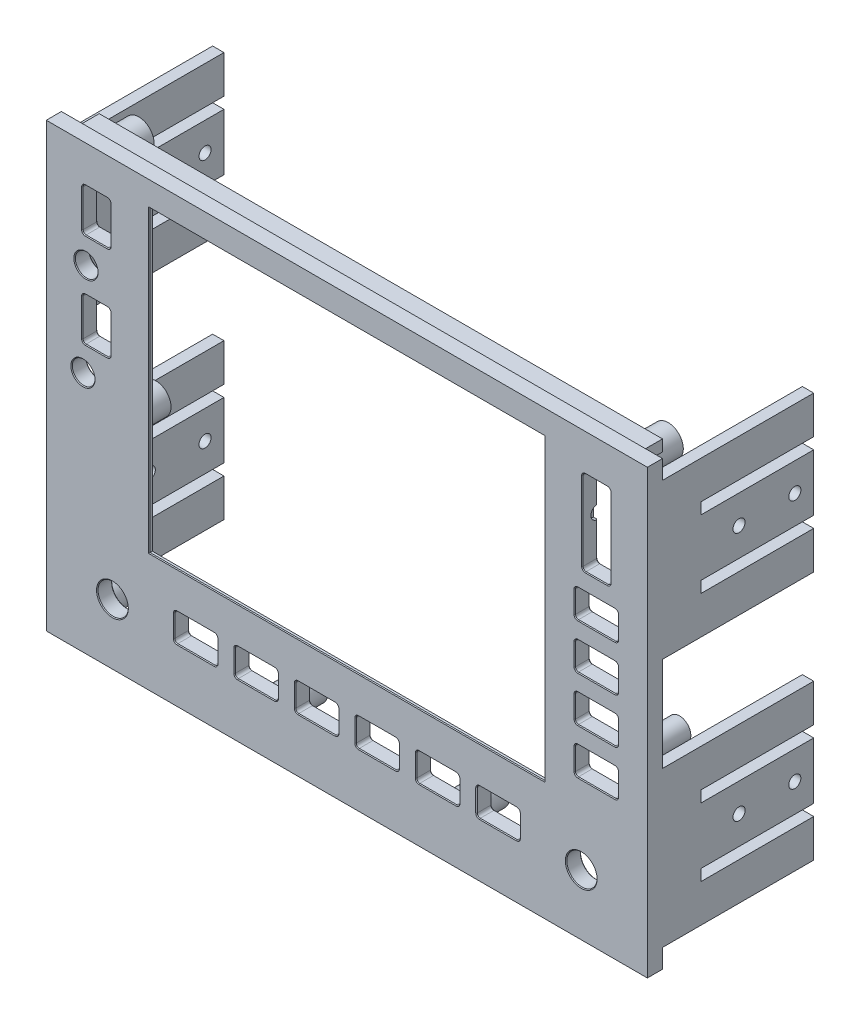
from build123d import *

# Parameters (mm, degrees)
ESQUISSE1_W                  = 160
ESQUISSE1_H                  = 117
BOSS_EXTRU_1_DEPTH           = 4
ESQUISSE3_W                  = 104.5
ESQUISSE3_H                  = 79
ENL_V_MAT_EXTRU_2_DEPTH      = 4
ESQUISSE14_W                 = 3
ESQUISSE14_H                 = 41
BOSS_EXTRU_3_DEPTH           = 40
ESQUISSE15_R                 = 1.6
ESQUISSE15_W                 = 29.751261147
ESQUISSE15_H                 = 3
ENL_V_MAT_EXTRU_8_DEPTH      = 161
ESQUISSE16_W                 = 31.071550454
ESQUISSE16_H                 = 132.180055176
ESQUISSE16_W_2               = 12.596574509
ESQUISSE16_H_2               = 136.043004691
ENL_V_MAT_EXTRU_9_DEPTH      = 45
ESQUISSE9_W                  = 118.5
ESQUISSE9_H                  = 89
ENL_V_MAT_EXTRU_5_DEPTH      = 3
ESQUISSE4_R                  = 4
ENL_V_MAT_EXTRU_3_DEPTH      = 4
ESQUISSE12_R                 = 4
ESQUISSE12_R_2               = 1.425
BOSS_EXTRU_2_DEPTH           = 11
ESQUISSE12_R_3               = 3
BOSS_EXTRU_2_2_DEPTH         = 11
BOSS_EXTRU_2_3_DEPTH         = 11
BOSS_EXTRU_2_4_DEPTH         = 11
BOSS_EXTRU_2_5_DEPTH         = 11
BOSS_EXTRU_2_6_DEPTH         = 11
BOSS_EXTRU_2_7_DEPTH         = 11
BOSS_EXTRU_2_8_DEPTH         = 11
BOSS_EXTRU_2_9_DEPTH         = 11
ESQUISSE10_R                 = 3
ENL_V_MAT_EXTRU_6_DEPTH      = 30
ENL_V_MAT_EXTRU_6_DEPTH_BACK = 4
ESQUISSE11_R                 = 1.75
ENL_V_MAT_EXTRU_7_DEPTH      = 8.5
ENL_V_MAT_EXTRU_7_DEPTH_BACK = 1.5
CHANFREIN2_SIZE              = 0.2
CHANFREIN3_SIZE              = 0.2
ESQUISSE17_W                 = 149
ESQUISSE17_H                 = 4
ESQUISSE17_H_2               = 3
BOSS_EXTRU_4_DEPTH           = 5


with BuildPart() as part:
    # Esquisse1 → Boss.-Extru.1 (new body)
    with BuildSketch(Plane.XY):
        with Locations((80, 58.5)):
            Rectangle(ESQUISSE1_W, ESQUISSE1_H)
    extrude(amount=BOSS_EXTRU_1_DEPTH)

    # Esquisse3 → Enlèv. mat.-Extru.2 (cut)
    with BuildSketch(Plane.XY.offset(4)):
        with Locations((80, 71)):
            Rectangle(ESQUISSE3_W, ESQUISSE3_H)
    extrude(amount=-ENL_V_MAT_EXTRU_2_DEPTH, mode=Mode.SUBTRACT)

    # Esquisse14 → Boss.-Extru.3 (add)
    with BuildSketch(Plane(origin=(0, 0, 0), x_dir=(-1, 0, 0), z_dir=(0, 0, -1))):
        with Locations((-158, 25.5)):
            Rectangle(ESQUISSE14_W, ESQUISSE14_H)
        with Locations((-158, 91.5)):
            Rectangle(ESQUISSE14_W, ESQUISSE14_H)
        with Locations((-2, 25.5)):
            Rectangle(ESQUISSE14_W, ESQUISSE14_H)
        with Locations((-2, 91.5)):
            Rectangle(ESQUISSE14_W, ESQUISSE14_H)
    extrude(amount=BOSS_EXTRU_3_DEPTH)

    # Esquisse15 → Enlèv. mat.-Extru.8 (cut, through all)
    with BuildSketch(Plane(origin=(160, 0, 0), x_dir=(0, 0, -1), z_dir=(1, 0, 0))):
        with Locations((35, 91.5)):
            Circle(ESQUISSE15_R)
        with Locations((35, 25.5)):
            Circle(ESQUISSE15_R)
        with Locations((20.248738853, 91.5)):
            Circle(ESQUISSE15_R)
        with Locations((20.248738853, 25.5)):
            Circle(ESQUISSE15_R)
        with Locations((25.124369426, 100.5)):
            Rectangle(ESQUISSE15_W, ESQUISSE15_H)
        with Locations((25.124369426, 82.5)):
            Rectangle(ESQUISSE15_W, ESQUISSE15_H)
        with Locations((25.124369426, 34.5)):
            Rectangle(ESQUISSE15_W, ESQUISSE15_H)
        with Locations((25.124369426, 16.5)):
            Rectangle(ESQUISSE15_W, ESQUISSE15_H)
    extrude(amount=-ENL_V_MAT_EXTRU_8_DEPTH, mode=Mode.SUBTRACT)

    # Esquisse16 → Enlèv. mat.-Extru.9 (cut, through all)
    with BuildSketch(Plane.XY.offset(4)):
        with Locations((-15.035775227, 59.507713461)):
            Rectangle(ESQUISSE16_W, ESQUISSE16_H)
        with Locations((165.798287254, 59.255781971)):
            Rectangle(ESQUISSE16_W_2, ESQUISSE16_H_2)
    extrude(amount=-ENL_V_MAT_EXTRU_9_DEPTH, mode=Mode.SUBTRACT)

    # Esquisse9 → Enlèv. mat.-Extru.5 (cut)
    with BuildSketch(Plane(origin=(0, 0, 0), x_dir=(-1, 0, 0), z_dir=(0, 0, -1))):
        with Locations((-80, 68.5)):
            Rectangle(ESQUISSE9_W, ESQUISSE9_H)
    extrude(amount=-ENL_V_MAT_EXTRU_5_DEPTH, mode=Mode.SUBTRACT)

    # Esquisse4 → Enlèv. mat.-Extru.3 (cut)
    with BuildSketch(Plane.XY.offset(4)):
        with Locations((142, 16)):
            Circle(ESQUISSE4_R)
        with Locations((18, 16)):
            Circle(ESQUISSE4_R)
    extrude(amount=-ENL_V_MAT_EXTRU_3_DEPTH, mode=Mode.SUBTRACT)

    # Esquisse10 → Enlèv. mat.-Extru.6 (cut, two sides)
    with BuildSketch(Plane(origin=(0, 0, 0), x_dir=(-1, 0, 0), z_dir=(0, 0, -1))) as enl_v_mat_extru_6_sk:
        with Locations((-11, 89)):
            Circle(ESQUISSE10_R)
        with Locations((-10.2, 64)):
            Circle(ESQUISSE10_R)
        with BuildLine():
            Line((-124.9, 21.7), (-115.1, 21.7))
            ThreePointArc((-115.1, 21.7), (-114.534314575, 21.465685425), (-114.3, 20.9))
            Line((-114.3, 20.9), (-114.3, 15.1))
            ThreePointArc((-114.3, 15.1), (-114.534314575, 14.534314575), (-115.1, 14.3))
            Line((-115.1, 14.3), (-124.9, 14.3))
            ThreePointArc((-124.9, 14.3), (-125.465685425, 14.534314575), (-125.7, 15.1))
            Line((-125.7, 15.1), (-125.7, 20.9))
            ThreePointArc((-125.7, 20.9), (-125.465685425, 21.465685425), (-124.9, 21.7))
        make_face()
        with BuildLine():
            Line((-108.9, 21.7), (-99.1, 21.7))
            ThreePointArc((-99.1, 21.7), (-98.534314575, 21.465685425), (-98.3, 20.9))
            Line((-98.3, 20.9), (-98.3, 15.1))
            ThreePointArc((-98.3, 15.1), (-98.534314575, 14.534314575), (-99.1, 14.3))
            Line((-99.1, 14.3), (-108.9, 14.3))
            ThreePointArc((-108.9, 14.3), (-109.465685425, 14.534314575), (-109.7, 15.1))
            Line((-109.7, 15.1), (-109.7, 20.9))
            ThreePointArc((-109.7, 20.9), (-109.465685425, 21.465685425), (-108.9, 21.7))
        make_face()
        with BuildLine():
            Line((-92.9, 21.7), (-83.1, 21.7))
            ThreePointArc((-83.1, 21.7), (-82.534314575, 21.465685425), (-82.3, 20.9))
            Line((-82.3, 20.9), (-82.3, 15.1))
            ThreePointArc((-82.3, 15.1), (-82.534314575, 14.534314575), (-83.1, 14.3))
            Line((-83.1, 14.3), (-92.9, 14.3))
            ThreePointArc((-92.9, 14.3), (-93.465685425, 14.534314575), (-93.7, 15.1))
            Line((-93.7, 15.1), (-93.7, 20.9))
            ThreePointArc((-93.7, 20.9), (-93.465685425, 21.465685425), (-92.9, 21.7))
        make_face()
        with BuildLine():
            Line((-76.9, 21.7), (-67.1, 21.7))
            ThreePointArc((-67.1, 21.7), (-66.534314575, 21.465685425), (-66.3, 20.9))
            Line((-66.3, 20.9), (-66.3, 15.1))
            ThreePointArc((-66.3, 15.1), (-66.534314575, 14.534314575), (-67.1, 14.3))
            Line((-67.1, 14.3), (-76.9, 14.3))
            ThreePointArc((-76.9, 14.3), (-77.465685425, 14.534314575), (-77.7, 15.1))
            Line((-77.7, 15.1), (-77.7, 20.9))
            ThreePointArc((-77.7, 20.9), (-77.465685425, 21.465685425), (-76.9, 21.7))
        make_face()
        with BuildLine():
            Line((-60.9, 21.7), (-51.1, 21.7))
            ThreePointArc((-51.1, 21.7), (-50.534314575, 21.465685425), (-50.3, 20.9))
            Line((-50.3, 20.9), (-50.3, 15.1))
            ThreePointArc((-50.3, 15.1), (-50.534314575, 14.534314575), (-51.1, 14.3))
            Line((-51.1, 14.3), (-60.9, 14.3))
            ThreePointArc((-60.9, 14.3), (-61.465685425, 14.534314575), (-61.7, 15.1))
            Line((-61.7, 15.1), (-61.7, 20.9))
            ThreePointArc((-61.7, 20.9), (-61.465685425, 21.465685425), (-60.9, 21.7))
        make_face()
        with BuildLine():
            Line((-44.9, 21.7), (-35.1, 21.7))
            ThreePointArc((-35.1, 21.7), (-34.534314575, 21.465685425), (-34.3, 20.9))
            Line((-34.3, 20.9), (-34.3, 15.1))
            ThreePointArc((-34.3, 15.1), (-34.534314575, 14.534314575), (-35.1, 14.3))
            Line((-35.1, 14.3), (-44.9, 14.3))
            ThreePointArc((-44.9, 14.3), (-45.465685425, 14.534314575), (-45.7, 15.1))
            Line((-45.7, 15.1), (-45.7, 20.9))
            ThreePointArc((-45.7, 20.9), (-45.465685425, 21.465685425), (-44.9, 21.7))
        make_face()
        with BuildLine():
            Line((-148.9, 107.2), (-143.1, 107.2))
            ThreePointArc((-143.1, 107.2), (-142.534314575, 106.965685425), (-142.3, 106.4))
            Line((-142.3, 106.4), (-142.3, 85.6))
            ThreePointArc((-142.3, 85.6), (-142.534314575, 85.034314575), (-143.1, 84.8))
            Line((-143.1, 84.8), (-148.9, 84.8))
            ThreePointArc((-148.9, 84.8), (-149.465685425, 85.034314575), (-149.7, 85.6))
            Line((-149.7, 85.6), (-149.7, 106.4))
            ThreePointArc((-149.7, 106.4), (-149.465685425, 106.965685425), (-148.9, 107.2))
        make_face()
        with BuildLine():
            Line((-150.9, 80.2), (-141.1, 80.2))
            ThreePointArc((-141.1, 80.2), (-140.534314575, 79.965685425), (-140.3, 79.4))
            Line((-140.3, 79.4), (-140.3, 73.6))
            ThreePointArc((-140.3, 73.6), (-140.534314575, 73.034314575), (-141.1, 72.8))
            Line((-141.1, 72.8), (-150.9, 72.8))
            ThreePointArc((-150.9, 72.8), (-151.465685425, 73.034314575), (-151.7, 73.6))
            Line((-151.7, 73.6), (-151.7, 79.4))
            ThreePointArc((-151.7, 79.4), (-151.465685425, 79.965685425), (-150.9, 80.2))
        make_face()
        with BuildLine():
            Line((-150.9, 68.2), (-141.1, 68.2))
            ThreePointArc((-141.1, 68.2), (-140.534314575, 67.965685425), (-140.3, 67.4))
            Line((-140.3, 67.4), (-140.3, 61.6))
            ThreePointArc((-140.3, 61.6), (-140.534314575, 61.034314575), (-141.1, 60.8))
            Line((-141.1, 60.8), (-150.9, 60.8))
            ThreePointArc((-150.9, 60.8), (-151.465685425, 61.034314575), (-151.7, 61.6))
            Line((-151.7, 61.6), (-151.7, 67.4))
            ThreePointArc((-151.7, 67.4), (-151.465685425, 67.965685425), (-150.9, 68.2))
        make_face()
        with BuildLine():
            Line((-150.9, 56.2), (-141.1, 56.2))
            ThreePointArc((-141.1, 56.2), (-140.534314575, 55.965685425), (-140.3, 55.4))
            Line((-140.3, 55.4), (-140.3, 49.6))
            ThreePointArc((-140.3, 49.6), (-140.534314575, 49.034314575), (-141.1, 48.8))
            Line((-141.1, 48.8), (-150.9, 48.8))
            ThreePointArc((-150.9, 48.8), (-151.465685425, 49.034314575), (-151.7, 49.6))
            Line((-151.7, 49.6), (-151.7, 55.4))
            ThreePointArc((-151.7, 55.4), (-151.465685425, 55.965685425), (-150.9, 56.2))
        make_face()
        with BuildLine():
            Line((-150.9, 44.2), (-141.1, 44.2))
            ThreePointArc((-141.1, 44.2), (-140.534314575, 43.965685425), (-140.3, 43.4))
            Line((-140.3, 43.4), (-140.3, 37.6))
            ThreePointArc((-140.3, 37.6), (-140.534314575, 37.034314575), (-141.1, 36.8))
            Line((-141.1, 36.8), (-150.9, 36.8))
            ThreePointArc((-150.9, 36.8), (-151.465685425, 37.034314575), (-151.7, 37.6))
            Line((-151.7, 37.6), (-151.7, 43.4))
            ThreePointArc((-151.7, 43.4), (-151.465685425, 43.965685425), (-150.9, 44.2))
        make_face()
        with BuildLine():
            Line((-16.65, 107.2), (-10.85, 107.2))
            ThreePointArc((-10.85, 107.2), (-10.284314575, 106.965685425), (-10.05, 106.4))
            Line((-10.05, 106.4), (-10.05, 96.6))
            ThreePointArc((-10.05, 96.6), (-10.284314575, 96.034314575), (-10.85, 95.8))
            Line((-10.85, 95.8), (-16.65, 95.8))
            ThreePointArc((-16.65, 95.8), (-17.215685425, 96.034314575), (-17.45, 96.6))
            Line((-17.45, 96.6), (-17.45, 106.4))
            ThreePointArc((-17.45, 106.4), (-17.215685425, 106.965685425), (-16.65, 107.2))
        make_face()
        with BuildLine():
            Line((-16.65, 82.2), (-10.85, 82.2))
            ThreePointArc((-10.85, 82.2), (-10.284314575, 81.965685425), (-10.05, 81.4))
            Line((-10.05, 81.4), (-10.05, 71.6))
            ThreePointArc((-10.05, 71.6), (-10.284314575, 71.034314575), (-10.85, 70.8))
            Line((-10.85, 70.8), (-16.65, 70.8))
            ThreePointArc((-16.65, 70.8), (-17.215685425, 71.034314575), (-17.45, 71.6))
            Line((-17.45, 71.6), (-17.45, 81.4))
            ThreePointArc((-17.45, 81.4), (-17.215685425, 81.965685425), (-16.65, 82.2))
        make_face()
    extrude(amount=ENL_V_MAT_EXTRU_6_DEPTH, mode=Mode.SUBTRACT)
    extrude(enl_v_mat_extru_6_sk.sketch, amount=-ENL_V_MAT_EXTRU_6_DEPTH_BACK, mode=Mode.SUBTRACT)

    # Esquisse11 → Enlèv. mat.-Extru.7 (cut, two sides)
    with BuildSketch(Plane.ZY.offset(-149.7)) as enl_v_mat_extru_7_sk:
        with Locations((0, 96.2)):
            Circle(ESQUISSE11_R)
    extrude(amount=ENL_V_MAT_EXTRU_7_DEPTH, mode=Mode.SUBTRACT)
    extrude(enl_v_mat_extru_7_sk.sketch, amount=-ENL_V_MAT_EXTRU_7_DEPTH_BACK, mode=Mode.SUBTRACT)

    # Chanfrein2
    chanfrein2_edges = [part.edges().sort_by_distance(p)[0] for p in [
        (80, 110.5, 4),
        (80, 31.5, 3),
        (139.25, 68.5, 0),
        (80, 24, 0),
        (20.75, 68.5, 0),
        (80, 113, 0),
        (80, 110.5, 3),
        (27.75, 71, 3),
        (132.25, 71, 3),
        (138, 16, 0),
        (138, 16, 4),
        (14, 16, 0),
        (14, 16, 4),
        (45.465685425, 14.534314575, 0),
        (45.465685425, 14.534314575, 4),
        (40, 14.3, 0),
        (40, 14.3, 4),
        (34.534314575, 14.534314575, 0),
        (34.534314575, 14.534314575, 4),
        (34.3, 18, 0),
        (34.3, 18, 4),
        (34.534314575, 21.465685425, 0),
        (34.534314575, 21.465685425, 4),
        (40, 21.7, 0),
        (40, 21.7, 4),
        (45.465685425, 21.465685425, 0),
        (45.465685425, 21.465685425, 4),
        (45.7, 18, 0),
        (45.7, 18, 4),
        (50.534314575, 21.465685425, 0),
        (50.534314575, 21.465685425, 4),
        (56, 21.7, 0),
        (56, 21.7, 4),
        (61.465685425, 21.465685425, 0),
        (61.465685425, 21.465685425, 4),
        (61.7, 18, 0),
        (61.7, 18, 4),
        (61.465685425, 14.534314575, 0),
        (61.465685425, 14.534314575, 4),
        (56, 14.3, 0),
        (56, 14.3, 4),
        (50.534314575, 14.534314575, 0),
        (50.534314575, 14.534314575, 4),
        (50.3, 18, 0),
        (50.3, 18, 4),
        (66.534314575, 21.465685425, 0),
        (66.534314575, 21.465685425, 4),
        (72, 21.7, 0),
        (72, 21.7, 4),
        (77.465685425, 21.465685425, 0),
        (77.465685425, 21.465685425, 4),
        (77.7, 18, 0),
        (77.7, 18, 4),
        (77.465685425, 14.534314575, 0),
        (77.465685425, 14.534314575, 4),
        (72, 14.3, 0),
        (72, 14.3, 4),
        (66.534314575, 14.534314575, 0),
        (66.534314575, 14.534314575, 4),
        (66.3, 18, 0),
        (66.3, 18, 4),
        (82.534314575, 21.465685425, 0),
        (82.534314575, 21.465685425, 4),
        (88, 21.7, 0),
        (88, 21.7, 4),
        (93.465685425, 21.465685425, 0),
        (93.465685425, 21.465685425, 4),
        (93.7, 18, 0),
        (93.7, 18, 4),
        (93.465685425, 14.534314575, 0),
        (93.465685425, 14.534314575, 4),
        (88, 14.3, 0),
        (88, 14.3, 4),
        (82.534314575, 14.534314575, 0),
        (82.534314575, 14.534314575, 4),
        (82.3, 18, 0),
        (82.3, 18, 4),
        (98.534314575, 21.465685425, 0),
        (98.534314575, 21.465685425, 4),
        (104, 21.7, 0),
        (104, 21.7, 4),
        (109.465685425, 21.465685425, 0),
        (109.465685425, 21.465685425, 4),
        (109.7, 18, 0),
        (109.7, 18, 4),
        (109.465685425, 14.534314575, 0),
        (109.465685425, 14.534314575, 4),
        (104, 14.3, 0),
        (104, 14.3, 4),
        (98.534314575, 14.534314575, 0),
        (98.534314575, 14.534314575, 4),
        (98.3, 18, 0),
        (98.3, 18, 4),
        (114.534314575, 21.465685425, 0),
        (114.534314575, 21.465685425, 4),
        (120, 21.7, 0),
        (120, 21.7, 4),
        (125.465685425, 21.465685425, 0),
        (125.465685425, 21.465685425, 4),
        (125.7, 18, 0),
        (125.7, 18, 4),
        (125.465685425, 14.534314575, 0),
        (125.465685425, 14.534314575, 4),
        (120, 14.3, 0),
        (120, 14.3, 4),
        (114.534314575, 14.534314575, 0),
        (114.534314575, 14.534314575, 4),
        (114.3, 18, 0),
        (114.3, 18, 4),
        (151.465685425, 43.965685425, 0),
        (151.465685425, 43.965685425, 4),
        (151.7, 40.5, 0),
        (151.7, 40.5, 4),
        (151.465685425, 37.034314575, 0),
        (151.465685425, 37.034314575, 4),
        (146, 36.8, 0),
        (146, 36.8, 4),
        (140.534314575, 37.034314575, 0),
        (140.534314575, 37.034314575, 4),
        (140.3, 40.5, 0),
        (140.3, 40.5, 4),
        (140.534314575, 43.965685425, 0),
        (140.534314575, 43.965685425, 4),
        (146, 44.2, 0),
        (146, 44.2, 4),
        (140.534314575, 55.965685425, 0),
        (140.534314575, 55.965685425, 4),
        (146, 56.2, 0),
        (146, 56.2, 4),
        (151.465685425, 55.965685425, 0),
        (151.465685425, 55.965685425, 4),
        (151.7, 52.5, 0),
        (151.7, 52.5, 4),
        (151.465685425, 49.034314575, 0),
        (151.465685425, 49.034314575, 4),
        (146, 48.8, 0),
        (146, 48.8, 4),
        (140.534314575, 49.034314575, 0),
        (140.534314575, 49.034314575, 4),
        (140.3, 52.5, 0),
        (140.3, 52.5, 4),
        (151.465685425, 67.965685425, 0),
        (151.465685425, 67.965685425, 4),
        (151.7, 64.5, 0),
        (151.7, 64.5, 4),
        (151.465685425, 61.034314575, 0),
        (151.465685425, 61.034314575, 4),
        (146, 60.8, 0),
        (146, 60.8, 4),
        (140.534314575, 61.034314575, 0),
        (140.534314575, 61.034314575, 4),
        (140.3, 64.5, 0),
        (140.3, 64.5, 4),
        (140.534314575, 67.965685425, 0),
        (140.534314575, 67.965685425, 4),
        (146, 68.2, 0),
        (146, 68.2, 4),
        (140.534314575, 73.034314575, 0),
        (140.534314575, 73.034314575, 4),
        (140.3, 76.5, 0),
        (140.3, 76.5, 4),
        (140.534314575, 79.965685425, 0),
        (140.534314575, 79.965685425, 4),
        (146, 80.2, 0),
        (146, 80.2, 4),
        (151.465685425, 79.965685425, 0),
        (151.465685425, 79.965685425, 4),
        (151.7, 76.5, 0),
        (151.7, 76.5, 4),
        (151.465685425, 73.034314575, 0),
        (151.465685425, 73.034314575, 4),
        (146, 72.8, 0),
        (146, 72.8, 4),
        (149.465685425, 85.034314575, 0),
        (149.465685425, 85.034314575, 4),
        (146, 84.8, 0),
        (146, 84.8, 4),
        (142.534314575, 85.034314575, 0),
        (142.534314575, 85.034314575, 4),
        (142.3, 102.175, 0),
        (142.3, 96, 4),
        (142.534314575, 106.965685425, 0),
        (142.534314575, 106.965685425, 4),
        (146, 107.2, 0),
        (146, 107.2, 4),
        (149.465685425, 106.965685425, 0),
        (149.465685425, 106.965685425, 4),
        (149.7, 90.025, 0),
        (149.7, 96, 4),
        (14, 89, 0),
        (14, 89, 4),
        (13.2, 64, 0),
        (13.2, 64, 4),
        (10.284314575, 81.965685425, 0),
        (10.284314575, 81.965685425, 4),
        (13.75, 82.2, 0),
        (13.75, 82.2, 4),
        (17.215685425, 81.965685425, 0),
        (17.215685425, 81.965685425, 4),
        (17.45, 76.5, 0),
        (17.45, 76.5, 4),
        (17.215685425, 71.034314575, 0),
        (17.215685425, 71.034314575, 4),
        (13.75, 70.8, 0),
        (13.75, 70.8, 4),
        (10.284314575, 71.034314575, 0),
        (10.284314575, 71.034314575, 4),
        (10.05, 76.5, 0),
        (10.05, 76.5, 4),
        (10.284314575, 96.034314575, 0),
        (10.284314575, 96.034314575, 4),
        (10.05, 101.5, 0),
        (10.05, 101.5, 4),
        (10.284314575, 106.965685425, 0),
        (10.284314575, 106.965685425, 4),
        (13.75, 107.2, 0),
        (13.75, 107.2, 4),
        (17.215685425, 106.965685425, 0),
        (17.215685425, 106.965685425, 4),
        (17.45, 101.5, 0),
        (17.45, 101.5, 4),
        (17.215685425, 96.034314575, 0),
        (17.215685425, 96.034314575, 4),
        (13.75, 95.8, 0),
        (13.75, 95.8, 4),
        (149.7, 102.175, 0),
        (142.3, 90.025, 0),
    ]]
    chamfer(chanfrein2_edges, length=CHANFREIN2_SIZE)

    # Chanfrein3
    chanfrein3_edges = [part.edges().sort_by_distance(p)[0] for p in [
        (132.25, 71, 4),
        (80, 31.5, 4),
        (27.75, 71, 4),
    ]]
    chamfer(chanfrein3_edges, length=CHANFREIN3_SIZE)

    # Esquisse17 → Boss.-Extru.4 (add)
    with BuildSketch(Plane(origin=(0, 0, 0), x_dir=(-1, 0, 0), z_dir=(0, 0, -1))):
        with Locations((-80, 2.5)):
            Rectangle(ESQUISSE17_W, ESQUISSE17_H)
        with Locations((-80, 115)):
            Rectangle(ESQUISSE17_W, ESQUISSE17_H_2)
    extrude(amount=BOSS_EXTRU_4_DEPTH)


with BuildPart() as body_2:
    # Esquisse12 → Boss.-Extru.2 (new body)
    with BuildSketch(Plane(origin=(0, 0, 0), x_dir=(-1, 0, 0), z_dir=(0, 0, -1))):
        with Locations((-150, 111)):
            Circle(ESQUISSE12_R)
        with Locations((-150, 111)):
            Circle(ESQUISSE12_R_2, mode=Mode.SUBTRACT)
    extrude(amount=BOSS_EXTRU_2_DEPTH)


with BuildPart() as body_3:
    # Esquisse12 → Boss.-Extru.2 2 (new body)
    with BuildSketch(Plane(origin=(0, 0, 0), x_dir=(-1, 0, 0), z_dir=(0, 0, -1))):
        with Locations((-153, 70.312347561)):
            Circle(ESQUISSE12_R_3)
        with Locations((-153, 70.312347561)):
            Circle(ESQUISSE12_R_2, mode=Mode.SUBTRACT)
    extrude(amount=BOSS_EXTRU_2_2_DEPTH)


with BuildPart() as body_4:
    # Esquisse12 → Boss.-Extru.2 3 (new body)
    with BuildSketch(Plane(origin=(0, 0, 0), x_dir=(-1, 0, 0), z_dir=(0, 0, -1))):
        with Locations((-152.999695464, 46.312347563)):
            Circle(ESQUISSE12_R_3)
        with Locations((-152.999695464, 46.312347563)):
            Circle(ESQUISSE12_R_2, mode=Mode.SUBTRACT)
    extrude(amount=BOSS_EXTRU_2_3_DEPTH)


with BuildPart() as body_5:
    # Esquisse12 → Boss.-Extru.2 4 (new body)
    with BuildSketch(Plane(origin=(0, 0, 0), x_dir=(-1, 0, 0), z_dir=(0, 0, -1))):
        with Locations((-152, 8)):
            Circle(ESQUISSE12_R)
        with Locations((-152, 8)):
            Circle(ESQUISSE12_R_2, mode=Mode.SUBTRACT)
    extrude(amount=BOSS_EXTRU_2_4_DEPTH)


with BuildPart() as body_6:
    # Esquisse12 → Boss.-Extru.2 5 (new body)
    with BuildSketch(Plane(origin=(0, 0, 0), x_dir=(-1, 0, 0), z_dir=(0, 0, -1))):
        with Locations((-104, 8)):
            Circle(ESQUISSE12_R)
        with Locations((-104, 8)):
            Circle(ESQUISSE12_R_2, mode=Mode.SUBTRACT)
    extrude(amount=BOSS_EXTRU_2_5_DEPTH)


with BuildPart() as body_7:
    # Esquisse12 → Boss.-Extru.2 6 (new body)
    with BuildSketch(Plane(origin=(0, 0, 0), x_dir=(-1, 0, 0), z_dir=(0, 0, -1))):
        with Locations((-56, 8)):
            Circle(ESQUISSE12_R)
        with Locations((-56, 8)):
            Circle(ESQUISSE12_R_2, mode=Mode.SUBTRACT)
    extrude(amount=BOSS_EXTRU_2_6_DEPTH)


with BuildPart() as body_8:
    # Esquisse12 → Boss.-Extru.2 7 (new body)
    with BuildSketch(Plane(origin=(0, 0, 0), x_dir=(-1, 0, 0), z_dir=(0, 0, -1))):
        with Locations((-8, 8)):
            Circle(ESQUISSE12_R)
        with Locations((-8, 8)):
            Circle(ESQUISSE12_R_2, mode=Mode.SUBTRACT)
    extrude(amount=BOSS_EXTRU_2_7_DEPTH)


with BuildPart() as body_9:
    # Esquisse12 → Boss.-Extru.2 8 (new body)
    with BuildSketch(Plane(origin=(0, 0, 0), x_dir=(-1, 0, 0), z_dir=(0, 0, -1))):
        with Locations((-14.5, 52.8)):
            Circle(ESQUISSE12_R)
        with Locations((-14.5, 52.8)):
            Circle(ESQUISSE12_R_2, mode=Mode.SUBTRACT)
    extrude(amount=BOSS_EXTRU_2_8_DEPTH)


with BuildPart() as body_10:
    # Esquisse12 → Boss.-Extru.2 9 (new body)
    with BuildSketch(Plane(origin=(0, 0, 0), x_dir=(-1, 0, 0), z_dir=(0, 0, -1))):
        with Locations((-10, 111)):
            Circle(ESQUISSE12_R)
        with Locations((-10, 111)):
            Circle(ESQUISSE12_R_2, mode=Mode.SUBTRACT)
    extrude(amount=BOSS_EXTRU_2_9_DEPTH)


solid = Compound([part.part, body_2.part, body_3.part, body_4.part, body_5.part, body_6.part, body_7.part, body_8.part, body_9.part, body_10.part])
